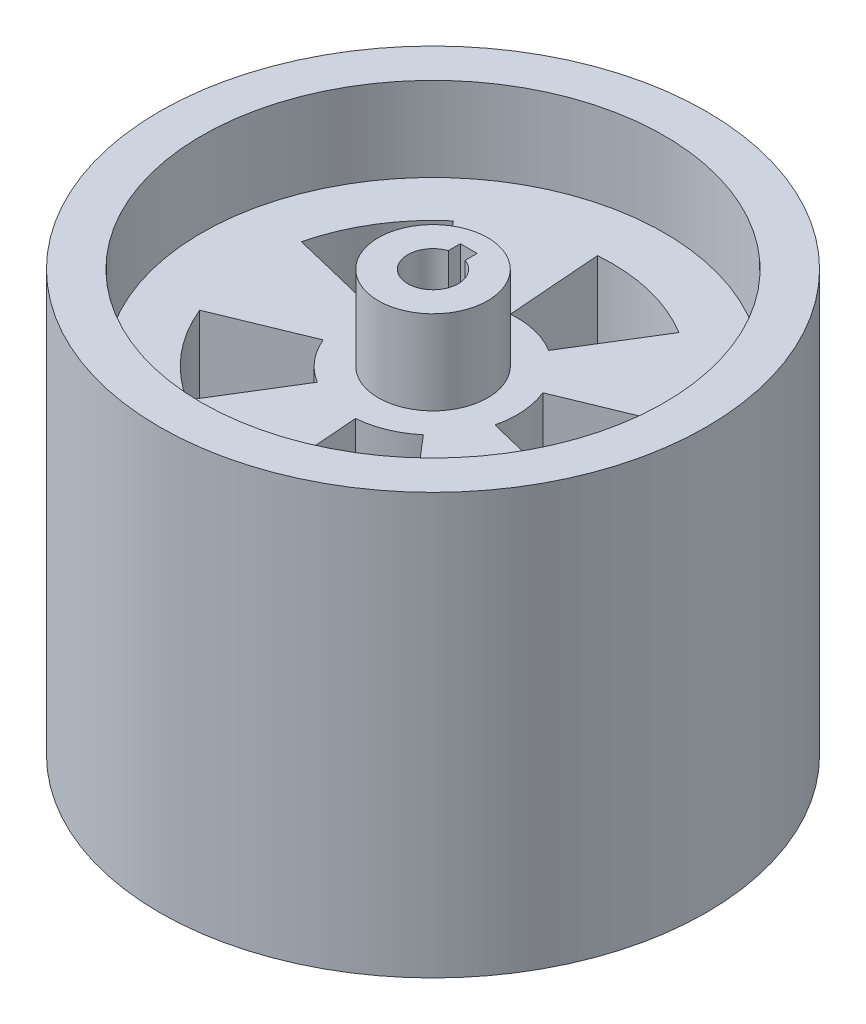
from build123d import *

# Parameters (mm, degrees)
SKETCH1_R           = 65
SKETCH1_R_2         = 55
BOSS_EXTRUDE1_DEPTH = 100
BOSS_EXTRUDE2_START = 20
SKETCH3_R           = 55
SKETCH3_R_2         = 13
BOSS_EXTRUDE2_DEPTH = 20
BOSS_EXTRUDE3_START = 60
SKETCH3_5_R         = 55
SKETCH3_5_R_2       = 13
BOSS_EXTRUDE3_DEPTH = 20
BOSS_EXTRUDE4_START = 20
SKETCH3_7_R         = 13
SKETCH3_7_R_2       = 6.5
BOSS_EXTRUDE4_DEPTH = 60
SKETCH3_10_R        = 13
BOSS_EXTRUDE5_DEPTH = 20
BOSS_EXTRUDE6_START = 80
SKETCH3_11_R        = 13
BOSS_EXTRUDE6_DEPTH = 20


with BuildPart() as part:
    # Sketch1 → Boss-Extrude1 (new body)
    with BuildSketch(Plane(origin=(0, 0, 0), x_dir=(1, 0, 0), z_dir=(0, 1, 0))):
        Circle(SKETCH1_R)
        Circle(SKETCH1_R_2, mode=Mode.SUBTRACT)
    extrude(amount=BOSS_EXTRUDE1_DEPTH)

    # Sketch3 → Boss-Extrude2 (add)
    with BuildSketch(Plane(origin=(0, 0, 0), x_dir=(1, 0, 0), z_dir=(0, 1, 0)).offset(BOSS_EXTRUDE2_START)):
        Circle(SKETCH3_R)
        with BuildLine():
            ThreePointArc((1.527466732, -19.941585829), (7.614996105, -18.493561969), (12.957116602, -15.235259412))
            Line((12.957116602, -15.235259412), (27.53387278, -32.374926251))
            ThreePointArc((27.53387278, -32.374926251), (16.181866723, -39.298819185), (3.245866806, -42.375869887))
            Line((3.245866806, -42.375869887), (1.527466732, -19.941585829))
        make_face(mode=Mode.SUBTRACT)
        with BuildLine():
            ThreePointArc((-18.493561969, -7.614996105), (-15.235259412, -12.957116602), (-10.485623513, -17.030904249))
            Line((-10.485623513, -17.030904249), (-22.281949965, -36.190671529))
            ThreePointArc((-22.281949965, -36.190671529), (-32.374926251, -27.53387278), (-39.298819185, -16.181866723))
            Line((-39.298819185, -16.181866723), (-18.493561969, -7.614996105))
        make_face(mode=Mode.SUBTRACT)
        with BuildLine():
            ThreePointArc((-12.957116602, 15.235259412), (-17.030904249, 10.485623513), (-19.437588327, 4.709581727))
            Line((-19.437588327, 4.709581727), (-41.304875194, 10.00786117))
            ThreePointArc((-41.304875194, 10.00786117), (-36.190671529, 22.281949965), (-27.53387278, 32.374926251))
            Line((-27.53387278, 32.374926251), (-12.957116602, 15.235259412))
        make_face(mode=Mode.SUBTRACT)
        with BuildLine():
            ThreePointArc((10.485623513, 17.030904249), (4.709581727, 19.437588327), (-1.527466732, 19.941585829))
            Line((-1.527466732, 19.941585829), (-3.245866806, 42.375869887))
            ThreePointArc((-3.245866806, 42.375869887), (10.00786117, 41.304875194), (22.281949965, 36.190671529))
            Line((22.281949965, 36.190671529), (10.485623513, 17.030904249))
        make_face(mode=Mode.SUBTRACT)
        with BuildLine():
            Line((18.493561969, 7.614996105), (39.298819185, 16.181866723))
            ThreePointArc((39.298819185, 16.181866723), (42.375869887, 3.245866806), (41.304875194, -10.00786117))
            Line((41.304875194, -10.00786117), (19.437588327, -4.709581727))
            ThreePointArc((19.437588327, -4.709581727), (19.941585829, 1.527466732), (18.493561969, 7.614996105))
        make_face(mode=Mode.SUBTRACT)
        Circle(SKETCH3_R_2, mode=Mode.SUBTRACT)
    extrude(amount=BOSS_EXTRUDE2_DEPTH)

    # Sketch3_5 → Boss-Extrude3 (add)
    with BuildSketch(Plane(origin=(0, 0, 0), x_dir=(1, 0, 0), z_dir=(0, 1, 0)).offset(BOSS_EXTRUDE3_START)):
        Circle(SKETCH3_5_R)
        with BuildLine():
            ThreePointArc((1.527466732, -19.941585829), (7.614996105, -18.493561969), (12.957116602, -15.235259412))
            Line((12.957116602, -15.235259412), (27.53387278, -32.374926251))
            ThreePointArc((27.53387278, -32.374926251), (16.181866723, -39.298819185), (3.245866806, -42.375869887))
            Line((3.245866806, -42.375869887), (1.527466732, -19.941585829))
        make_face(mode=Mode.SUBTRACT)
        with BuildLine():
            ThreePointArc((-18.493561969, -7.614996105), (-15.235259412, -12.957116602), (-10.485623513, -17.030904249))
            Line((-10.485623513, -17.030904249), (-22.281949965, -36.190671529))
            ThreePointArc((-22.281949965, -36.190671529), (-32.374926251, -27.53387278), (-39.298819185, -16.181866723))
            Line((-39.298819185, -16.181866723), (-18.493561969, -7.614996105))
        make_face(mode=Mode.SUBTRACT)
        with BuildLine():
            ThreePointArc((-12.957116602, 15.235259412), (-17.030904249, 10.485623513), (-19.437588327, 4.709581727))
            Line((-19.437588327, 4.709581727), (-41.304875194, 10.00786117))
            ThreePointArc((-41.304875194, 10.00786117), (-36.190671529, 22.281949965), (-27.53387278, 32.374926251))
            Line((-27.53387278, 32.374926251), (-12.957116602, 15.235259412))
        make_face(mode=Mode.SUBTRACT)
        with BuildLine():
            ThreePointArc((10.485623513, 17.030904249), (4.709581727, 19.437588327), (-1.527466732, 19.941585829))
            Line((-1.527466732, 19.941585829), (-3.245866806, 42.375869887))
            ThreePointArc((-3.245866806, 42.375869887), (10.00786117, 41.304875194), (22.281949965, 36.190671529))
            Line((22.281949965, 36.190671529), (10.485623513, 17.030904249))
        make_face(mode=Mode.SUBTRACT)
        with BuildLine():
            Line((18.493561969, 7.614996105), (39.298819185, 16.181866723))
            ThreePointArc((39.298819185, 16.181866723), (42.375869887, 3.245866806), (41.304875194, -10.00786117))
            Line((41.304875194, -10.00786117), (19.437588327, -4.709581727))
            ThreePointArc((19.437588327, -4.709581727), (19.941585829, 1.527466732), (18.493561969, 7.614996105))
        make_face(mode=Mode.SUBTRACT)
        Circle(SKETCH3_5_R_2, mode=Mode.SUBTRACT)
    extrude(amount=BOSS_EXTRUDE3_DEPTH)

    # Sketch3_7 → Boss-Extrude4 (add)
    with BuildSketch(Plane(origin=(0, 0, 0), x_dir=(1, 0, 0), z_dir=(0, 1, 0)).offset(BOSS_EXTRUDE4_START)):
        Circle(SKETCH3_7_R)
        Circle(SKETCH3_7_R_2, mode=Mode.SUBTRACT)
    extrude(amount=BOSS_EXTRUDE4_DEPTH)

    # Sketch3_10 → Boss-Extrude5 (add)
    with BuildSketch(Plane(origin=(0, 0, 0), x_dir=(1, 0, 0), z_dir=(0, 1, 0))):
        Circle(SKETCH3_10_R)
        with BuildLine():
            ThreePointArc((2, 5.656854249), (0, -6), (-2, 5.656854249))
            Line((-2, 5.656854249), (-2, 8.5))
            Line((-2, 8.5), (2, 8.5))
            Line((2, 8.5), (2, 5.656854249))
        make_face(mode=Mode.SUBTRACT)
    extrude(amount=BOSS_EXTRUDE5_DEPTH)

    # Sketch3_11 → Boss-Extrude6 (add)
    with BuildSketch(Plane(origin=(0, 0, 0), x_dir=(1, 0, 0), z_dir=(0, 1, 0)).offset(BOSS_EXTRUDE6_START)):
        Circle(SKETCH3_11_R)
        with BuildLine():
            ThreePointArc((2, 5.656854249), (0, -6), (-2, 5.656854249))
            Line((-2, 5.656854249), (-2, 8.5))
            Line((-2, 8.5), (2, 8.5))
            Line((2, 8.5), (2, 5.656854249))
        make_face(mode=Mode.SUBTRACT)
    extrude(amount=BOSS_EXTRUDE6_DEPTH)


solid = part.part
